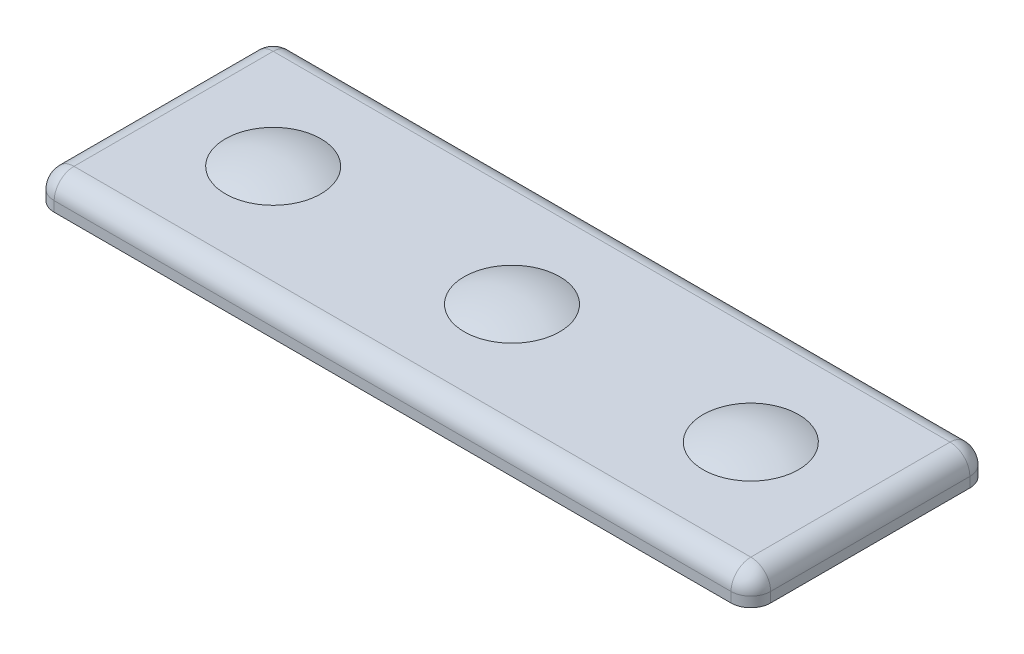
from build123d import *

# Parameters (mm, degrees)
BOSS_EXTRUDE1_START = 2.820416
SKETCH3_W           = 76.2
SKETCH3_H           = 25.4
SKETCH3_R           = 3.2639
BOSS_EXTRUDE1_DEPTH = 3.175
FILLET1_R           = 2.1082
CUT_EXTRUDE1_DEPTH  = 12.383516
LPATTERN1_COUNT     = 3
LPATTERN1_PITCH     = 25.4


with BuildPart() as part:
    # Sketch3 → Boss-Extrude1 (new body)
    with BuildSketch(Plane(origin=(0, 0, 0), x_dir=(1, 0, 0), z_dir=(0, 1, 0)).offset(BOSS_EXTRUDE1_START)):
        Rectangle(SKETCH3_W, SKETCH3_H)
        with Locations((-25.4, 0)):
            Circle(SKETCH3_R, mode=Mode.SUBTRACT)
        with Locations((25.4, 0)):
            Circle(SKETCH3_R, mode=Mode.SUBTRACT)
        Circle(SKETCH3_R, mode=Mode.SUBTRACT)
    extrude(amount=BOSS_EXTRUDE1_DEPTH)

    # Fillet1
    fillet1_edges = [part.edges().sort_by_distance(p)[0] for p in [
        (0, 5.995416, -12.7),
        (38.1, 5.995416, 0),
        (0, 5.995416, 12.7),
        (-38.1, 5.995416, 0),
        (-38.1, 4.407916, -12.7),
        (38.1, 4.407916, -12.7),
        (38.1, 4.407916, 12.7),
        (-38.1, 4.407916, 12.7),
    ]]
    fillet(fillet1_edges, radius=FILLET1_R)


with BuildPart() as body_2:
    # Sketch5 → Revolve1 (revolve)
    with BuildSketch(Plane.XY):
        with BuildLine():
            Line((-30.48, 5.995416), (-27.0002, 5.995416))
            Line((-27.0002, 5.995416), (-27.0002, 2.396612882))
            Line((-27.0002, 2.396612882), (-28.448, 2.953531234))
            Line((-28.448, 2.953531234), (-27.0002, 1.421990306))
            Line((-27.0002, 1.421990306), (-27.0002, 0.913990306))
            Line((-27.0002, 0.913990306), (-28.448, 1.470908658))
            Line((-28.448, 1.470908658), (-27.0002, -0.060632271))
            Line((-27.0002, -0.060632271), (-27.0002, -0.568632271))
            Line((-27.0002, -0.568632271), (-28.448, -0.011713918))
            Line((-28.448, -0.011713918), (-27.0002, -1.543254847))
            Line((-27.0002, -1.543254847), (-27.0002, -2.051254847))
            Line((-27.0002, -2.051254847), (-28.448, -1.494336495))
            Line((-28.448, -1.494336495), (-27.0002, -3.025877424))
            Line((-27.0002, -3.025877424), (-27.0002, -3.533877424))
            Line((-27.0002, -3.533877424), (-28.448, -2.976959071))
            Line((-28.448, -2.976959071), (-27.0002, -4.5085))
            Line((-27.0002, -4.5085), (-28.448, -4.5085))
            Line((-28.448, -4.5085), (-27.058882759, -6.0579))
            Line((-27.058882759, -6.0579), (-27.058882759, -6.3881))
            Line((-27.058882759, -6.3881), (-27.185882759, -6.3881))
            Line((-27.185882759, -6.3881), (-26.5938, -7.0485))
            Line((-26.5938, -7.0485), (-25.4, -7.0485))
            Line((-25.4, -7.0485), (-25.4, 7.0485))
            ThreePointArc((-25.4, 7.0485), (-27.99400202, 6.782459783), (-30.48, 5.995416))
        make_face()
    revolve(axis=Axis((-25.4, -7.0485, 0), (0, 1, 0)))

    # Sketch6 → Cut-Extrude1 (cut)
    with BuildSketch(Plane.XZ.offset(-5.995416)):
        with BuildLine():
            Line((-23.753680809, 5.08), (-27.046319191, 5.08))
            Line((-27.046319191, 5.08), (-26.035, 1.468814161))
            ThreePointArc((-26.035, 1.468814161), (-25.4, 1.6002), (-24.765, 1.468814161))
            Line((-24.765, 1.468814161), (-23.753680809, 5.08))
        make_face()
    extrude(amount=CUT_EXTRUDE1_DEPTH, mode=Mode.SUBTRACT)


with BuildPart() as lpattern1_1:
    # LPattern1: pattern copy
    add(body_2.part.moved(Location(Vector(1, 0, 0) * (1 * LPATTERN1_PITCH))))


with BuildPart() as lpattern1_2:
    # LPattern1: pattern copy
    add(body_2.part.moved(Location(Vector(1, 0, 0) * (2 * LPATTERN1_PITCH))))


solid = Compound([part.part, body_2.part, lpattern1_1.part, lpattern1_2.part])
